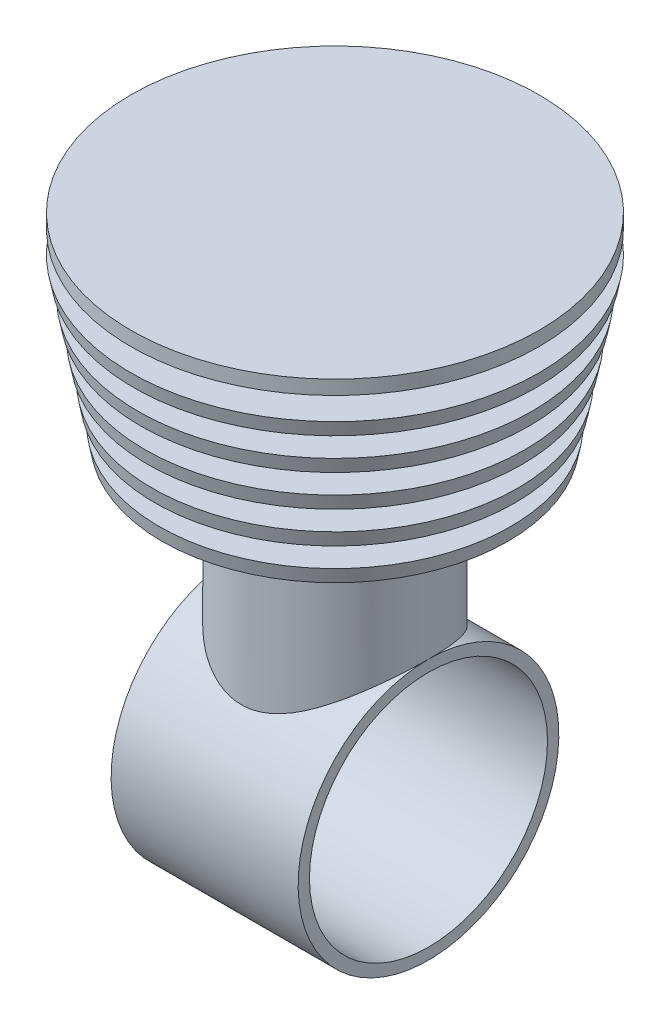
from build123d import *

# Parameters (mm, degrees)
ESQUISSE1_W             = 33
ESQUISSE1_H             = 2
BOSS_EXTRU_1_REACH      = 80.689
ESQUISSE5_R             = 16.5
ESQUISSE5_R_2           = 13.5
ENL_V_MAT_EXTRU_1_REACH = 80.689
ESQUISSE6_R             = 13.5


with BuildPart() as part:
    # Esquisse1 → Révolution1 (revolve)
    with BuildSketch(Plane.XY, mode=Mode.PRIVATE) as r_volution1_sk:
        with Locations((0, -1)):
            Rectangle(ESQUISSE1_W, ESQUISSE1_H)
    revolve(r_volution1_sk.sketch.rotate(Axis((0, -23, 0), (1, 0, 0)), 90), axis=Axis((0, -23, 0), (1, 0, 0)))

    # Esquisse5 → Boss.-Extru.1 (add, up to next)
    with BuildSketch(Plane.XZ, mode=Mode.PRIVATE) as boss_extru_1_sk1:
        with Locations(Location((0, 0, 0), (0, 0, 180))):
            Circle(ESQUISSE5_R)
        with Locations(Location((0, 0, 0), (0, 0, 180))):
            Circle(ESQUISSE5_R_2, mode=Mode.SUBTRACT)
    boss_extru_1_tool1 = extrude(boss_extru_1_sk1.sketch, amount=BOSS_EXTRU_1_REACH, mode=Mode.PRIVATE) - part.part


with BuildPart() as body_2:
    # Esquisse2 → Révolution2 (revolve)
    with BuildSketch(Plane.XY):
        Polygon((-16.5, 0), (-16.5, 25), (-36, 25), (-36, 27.5), (-16.5, 27.5), (-16.5, 31.5), (-36, 31.5), (-36, 34), (-16.5, 34), (-16.5, 38), (-36, 38), (-36, 40.5), (-23.5, 40.5), (-23.5, 44.5), (-36, 44.5), (-36, 47), (-23.5, 47), (-23.5, 51), (-36, 51), (-36, 53.5), (-23.5, 53.5), (-23.5, 57.5), (-36, 57.5), (-36, 60), (0, 60), (0, 56), (-13.5, 56), (-13.5, 0), align=None)
    revolve(axis=Axis((0, 56, 0), (0, -1, 0)))

    # Esquisse4 → Enlèvement de matière-Révolution1 (revolve, cut)
    with BuildSketch(Plane.XY, mode=Mode.PRIVATE) as enl_vement_de_mati_re_r_volution1_sk:
        Polygon((-36, 60), (-36, 53.5), (-30.5, 25), (-37, 25), (-37, 60), align=None)
    revolve(enl_vement_de_mati_re_r_volution1_sk.sketch.rotate(Axis((0, 0, 0), (0, 1, 0)), 180), axis=Axis((0, 0, 0), (0, 1, 0)), mode=Mode.SUBTRACT)


with BuildPart() as part_1:
    add(part.part)

    add(body_2.part)  # Boss.-Extru.1 merges body 2
    add(boss_extru_1_tool1.solids().sort_by_distance((16.03331, 0, 0))[0])
    add(boss_extru_1_tool1.solids().sort_by_distance((16.03331, 0, 0))[1])

    # Esquisse6 → Enlèv. mat.-Extru.1 (cut, up to next)
    with BuildSketch(Plane(origin=(0, 0, 0), x_dir=(1, 0, 0), z_dir=(0, 1, 0)), mode=Mode.PRIVATE) as enl_v_mat_extru_1_sk1:
        with Locations(Location((0, 0, 0), (0, 0, 180))):
            Circle(ESQUISSE6_R)
    enl_v_mat_extru_1_tool1 = extrude(enl_v_mat_extru_1_sk1.sketch, amount=-ENL_V_MAT_EXTRU_1_REACH, mode=Mode.PRIVATE) & part_1.part
    add(enl_v_mat_extru_1_tool1.solids().sort_by_distance((0, 0, 0))[0], mode=Mode.SUBTRACT)


solid = part_1.part
